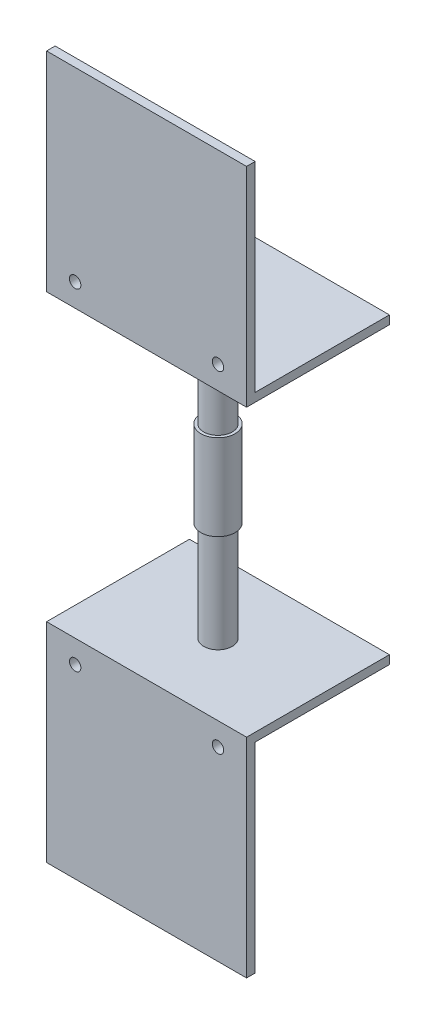
from build123d import *

# Parameters (mm, degrees)
SKETCH1_W           = 70
SKETCH1_H           = 50
BOSS_EXTRUDE1_DEPTH = 3
SKETCH2_W           = 70
SKETCH2_H           = 3
BOSS_EXTRUDE2_DEPTH = 70
SKETCH3_R           = 2
CUT_EXTRUDE1_DEPTH  = 6
SKETCH4_R           = 5
BOSS_EXTRUDE3_DEPTH = 35
SKETCH5_R           = 6
BOSS_EXTRUDE4_DEPTH = 30
SKETCH6_R           = 5
BOSS_EXTRUDE5_DEPTH = 35
SKETCH7_W           = 70
SKETCH7_H           = 50
BOSS_EXTRUDE6_DEPTH = 3
SKETCH8_W           = 70
SKETCH8_H           = 3
BOSS_EXTRUDE7_DEPTH = 70
SKETCH9_R           = 2
CUT_EXTRUDE2_DEPTH  = 70


with BuildPart() as part:
    # Sketch1 → Boss-Extrude1 (new body)
    with BuildSketch(Plane(origin=(0, 0, 0), x_dir=(1, 0, 0), z_dir=(0, 1, 0))):
        Rectangle(SKETCH1_W, SKETCH1_H)
    extrude(amount=BOSS_EXTRUDE1_DEPTH)

    # Sketch2 → Boss-Extrude2 (add)
    with BuildSketch(Plane(origin=(0, 3, 0), x_dir=(1, 0, 0), z_dir=(0, 1, 0))):
        with Locations((0, -23.5)):
            Rectangle(SKETCH2_W, SKETCH2_H)
    extrude(amount=BOSS_EXTRUDE2_DEPTH)

    # Sketch3 → Cut-Extrude1 (cut)
    with BuildSketch(Plane(origin=(0, 0, 22), x_dir=(-1, 0, 0), z_dir=(0, 0, -1))):
        with Locations((25, 8)):
            Circle(SKETCH3_R)
        with Locations((-25, 8)):
            Circle(SKETCH3_R)
    extrude(amount=-CUT_EXTRUDE1_DEPTH, mode=Mode.SUBTRACT)

    # Sketch4 → Boss-Extrude3 (add)
    with BuildSketch(Plane.XZ):
        Circle(SKETCH4_R)
    extrude(amount=BOSS_EXTRUDE3_DEPTH)

    # Sketch5 → Boss-Extrude4 (add)
    with BuildSketch(Plane.XZ.offset(35)):
        Circle(SKETCH5_R)
    extrude(amount=BOSS_EXTRUDE4_DEPTH)

    # Sketch6 → Boss-Extrude5 (add)
    with BuildSketch(Plane.XZ.offset(65)):
        Circle(SKETCH6_R)
    extrude(amount=BOSS_EXTRUDE5_DEPTH)

    # Sketch7 → Boss-Extrude6 (add)
    with BuildSketch(Plane.XZ.offset(100)):
        Rectangle(SKETCH7_W, SKETCH7_H)
    extrude(amount=BOSS_EXTRUDE6_DEPTH)

    # Sketch8 → Boss-Extrude7 (add)
    with BuildSketch(Plane.XZ.offset(103)):
        with Locations((0, 23.5)):
            Rectangle(SKETCH8_W, SKETCH8_H)
    extrude(amount=BOSS_EXTRUDE7_DEPTH)

    # Sketch9 → Cut-Extrude2 (cut)
    with BuildSketch(Plane(origin=(0, 0, 22), x_dir=(-1, 0, 0), z_dir=(0, 0, -1))):
        with Locations((-25, -108)):
            Circle(SKETCH9_R)
        with Locations((25, -108)):
            Circle(SKETCH9_R)
    extrude(amount=-CUT_EXTRUDE2_DEPTH, mode=Mode.SUBTRACT)


solid = part.part
